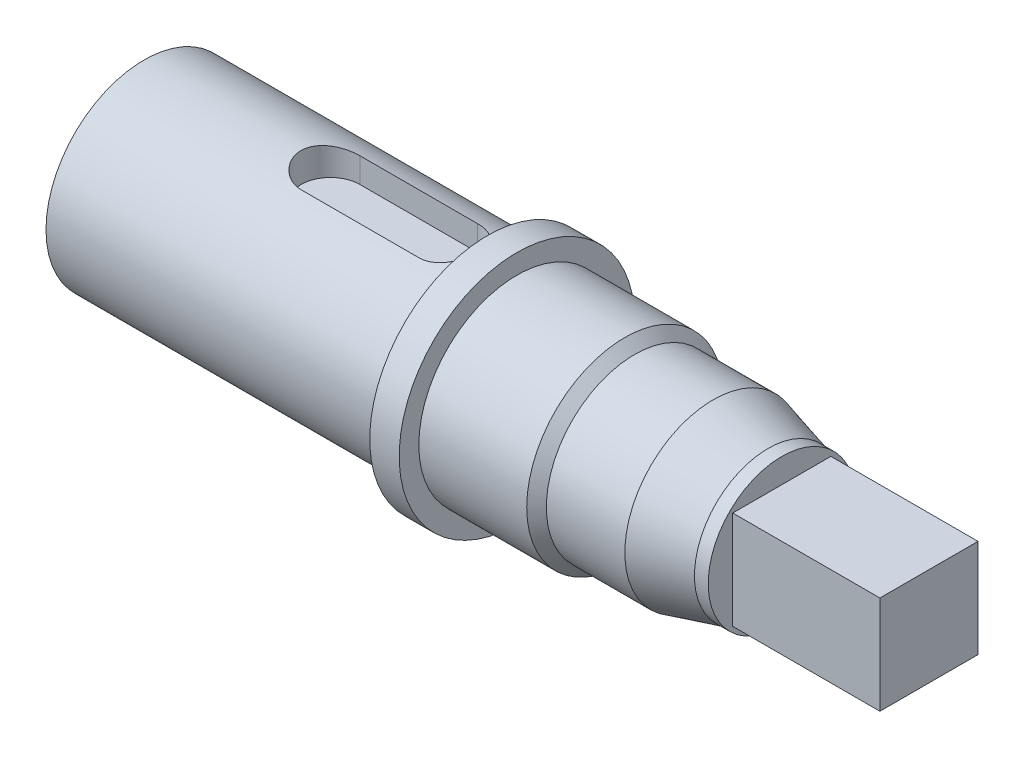
from build123d import *

# Parameters (mm, degrees)
SKETCH_2_OUTSIDE_W   = 43.38
SKETCH_2_OUTSIDE_H   = 43.38
SKETCH_2_OUTSIDE_W_2 = 10
SKETCH_2_OUTSIDE_H_2 = 10
CUT_EXTRUDE_1_DEPTH  = 15
CUT_EXTRUDE_START    = 7
CUT_EXTRUDE_2_DEPTH  = 6


with BuildPart() as part:
    # Эскиз1 → Повернуть1 (revolve)
    with BuildSketch(Plane.XY):
        Polygon((-25, 10), (10, 10), (10, 12), (13, 12), (13, 10), (24, 10), (25, 9), (33, 9), (38.598076211, 7.5), (55, 7.5), (55, 0), (-25, 0), align=None)
    revolve(axis=Axis((0, 0, 0), (-1, 0, 0)))

    # Эскиз2 outside → Вырез-Вытянуть1 (cut)
    with BuildSketch(Plane(origin=(55, 0, 0), x_dir=(0, 0, -1), z_dir=(1, 0, 0))):
        Rectangle(SKETCH_2_OUTSIDE_W, SKETCH_2_OUTSIDE_H)
        Rectangle(SKETCH_2_OUTSIDE_W_2, SKETCH_2_OUTSIDE_H_2, mode=Mode.SUBTRACT)
    extrude(amount=-CUT_EXTRUDE_1_DEPTH, mode=Mode.SUBTRACT)

    # Эскиз3 → Вырез-Вытянуть2 (cut, through all)
    with BuildSketch(Plane(origin=(0, 0, 0), x_dir=(1, 0, 0), z_dir=(0, 1, 0)).offset(CUT_EXTRUDE_START)):
        with BuildLine():
            Line((-6, 3), (6, 3))
            ThreePointArc((6, 3), (9, 0), (6, -3))
            Line((6, -3), (-6, -3))
            ThreePointArc((-6, -3), (-9, 0), (-6, 3))
        make_face()
    extrude(amount=CUT_EXTRUDE_2_DEPTH, mode=Mode.SUBTRACT)


solid = part.part
